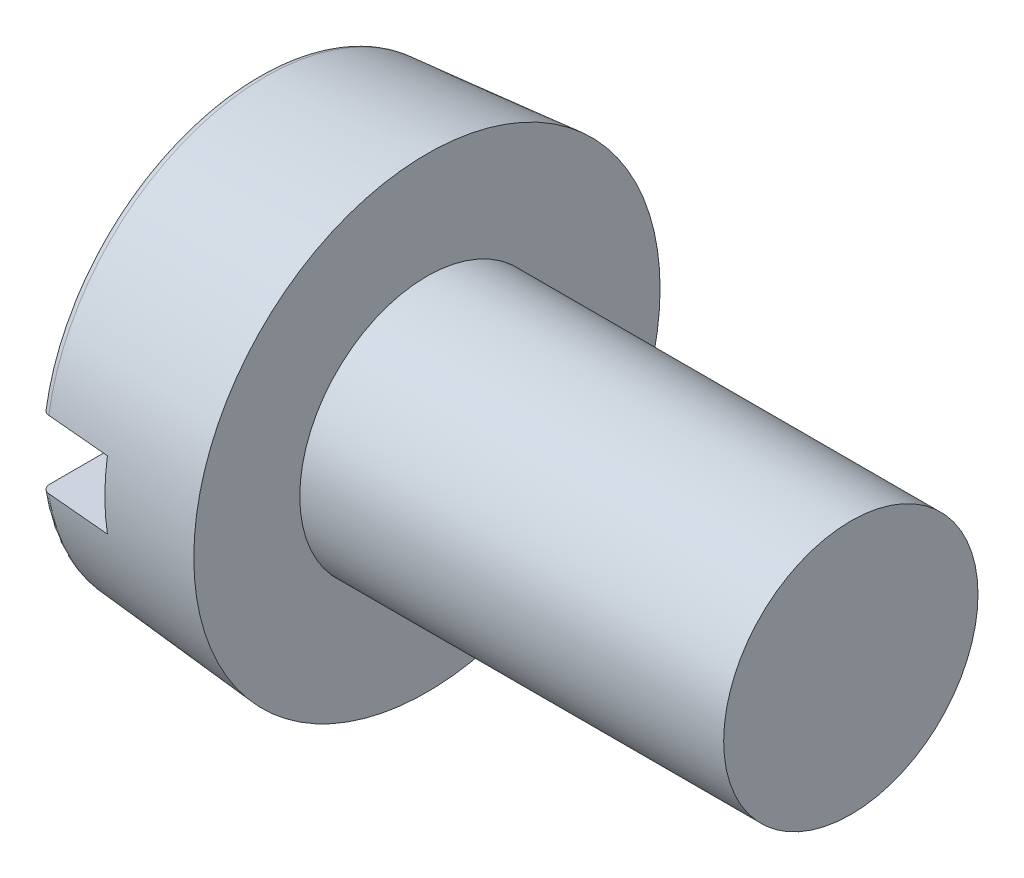
from build123d import *

# Parameters (mm, degrees)
FILLET2_R  = 0.1
SKETCH2_W  = 5.5
SKETCH2_H  = 0.8
SLOT_DEPTH = 0.85


with BuildPart() as part:
    # BodySke → Base-Revolve (revolve)
    with BuildSketch(Plane.XY):
        Polygon((2, 1.5), (2, 2.75), (0, 2.575022673), (0, 0), (7, 0), (7, 1.5), align=None)
    revolve(axis=Axis((-25.4, 0, 0), (1, 0, 0)))

    # Fillet2
    fillet2_edges = [part.edges().sort_by_distance(p)[0] for p in [
        (0, -2.575022673, 0),
    ]]
    fillet(fillet2_edges, radius=FILLET2_R)

    # Sketch2 → Slot (cut)
    with BuildSketch(Plane(origin=(0, 0, 0), x_dir=(0, 0, -1), z_dir=(1, 0, 0))):
        Rectangle(SKETCH2_W, SKETCH2_H)
    extrude(amount=SLOT_DEPTH, mode=Mode.SUBTRACT)


solid = part.part
